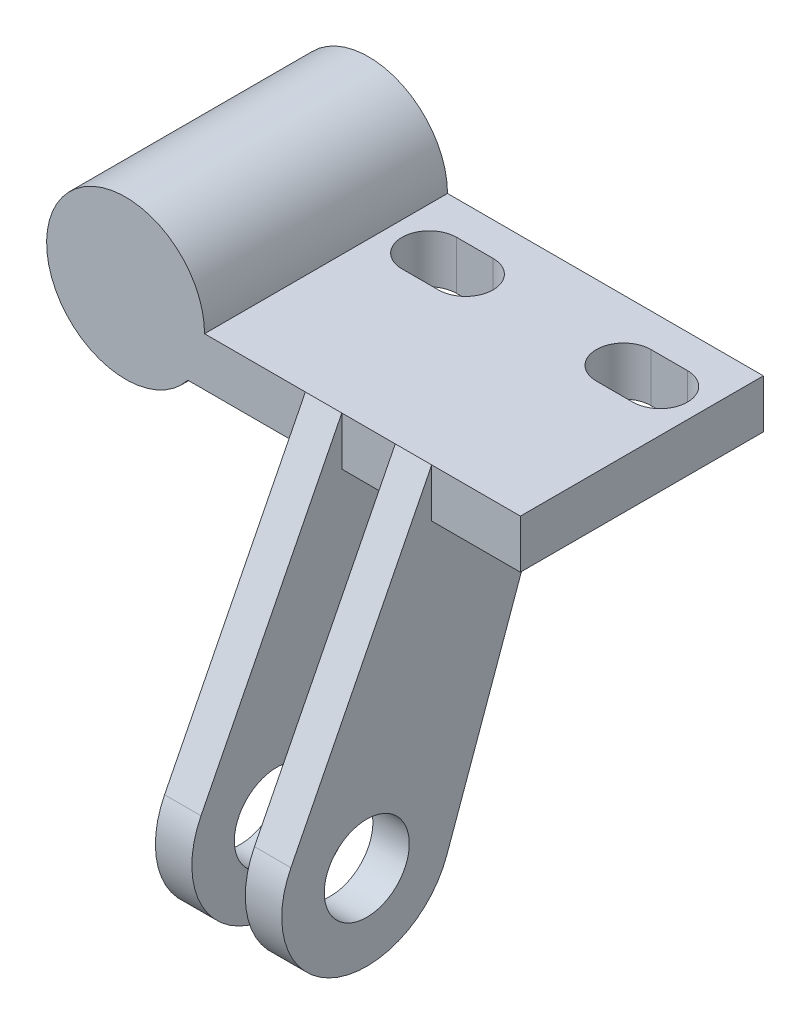
from build123d import *

# Parameters (mm, degrees)
SKETCH_1_R          = 4.1
EXTRUDE_1_DEPTH     = 20
SKETCH_2_R          = 4.923200542
EXTRUDE_2_DEPTH     = 3
CUT_EXTRUDE_1_DEPTH = 13
SKETCH_6_R          = 3.5
EXTRUDE_3_DEPTH     = 3


with BuildPart() as part:
    # Эскиз1 → Бобышка-Вытянуть1 (new body)
    with BuildSketch(Plane.XY):
        with BuildLine():
            Line((5.123475383, -4), (32.5, -4))
            Line((32.5, -4), (32.5, 0))
            Line((32.5, 0), (6.5, 0))
            ThreePointArc((6.5, 0), (-6.146242348, 2.115113473), (5.123475383, -4))
        make_face()
        Circle(SKETCH_1_R, mode=Mode.SUBTRACT)
    extrude(amount=EXTRUDE_1_DEPTH)

    # Эскиз2 → Бобышка-Вытянуть2 (add)
    with BuildSketch(Plane.XY.offset(20)):
        Circle(SKETCH_2_R)
    extrude(amount=-EXTRUDE_2_DEPTH)

    # Эскиз3 → Вырез-Вытянуть1 (cut)
    with BuildSketch(Plane(origin=(0, 0, 0), x_dir=(1, 0, 0), z_dir=(0, 1, 0))):
        with BuildLine():
            Line((10, -7.25), (13, -7.25))
            ThreePointArc((13, -7.25), (15.25, -5), (13, -2.75))
            Line((13, -2.75), (10, -2.75))
            ThreePointArc((10, -2.75), (7.75, -5), (10, -7.25))
        make_face()
        with BuildLine():
            Line((26, -2.75), (29, -2.75))
            ThreePointArc((29, -2.75), (31.25, -5), (29, -7.25))
            Line((29, -7.25), (26, -7.25))
            ThreePointArc((26, -7.25), (23.75, -5), (26, -2.75))
        make_face()
    extrude(amount=-CUT_EXTRUDE_1_DEPTH, mode=Mode.SUBTRACT)

    # Эскиз6 → Бобышка-Вытянуть3 (add)
    with BuildSketch(Plane(origin=(22.2, 0, 0), x_dir=(0, 0, -1), z_dir=(1, 0, 0))):
        with BuildLine():
            Line((-31.59202383, -22.918584172), (-20, 0))
            Line((-20, 0), (-10, -4))
            Line((-10, -4), (-18.755733241, -28.438927439))
            ThreePointArc((-18.755733241, -28.438927439), (-28.111077184, -32.508536772), (-31.59202383, -22.918584172))
        make_face()
        with Locations((-25.34557078, -26.077986693)):
            Circle(SKETCH_6_R, mode=Mode.SUBTRACT)
    extrude_3 = extrude(amount=EXTRUDE_3_DEPTH)

    # Зеркальное отражение1: Бобышка-Вытянуть3 across plane
    add(extrude_3.mirror(Plane(origin=(20, 0, 0), x_dir=(0, 0, 1), z_dir=(1, 0, 0))))


solid = part.part
